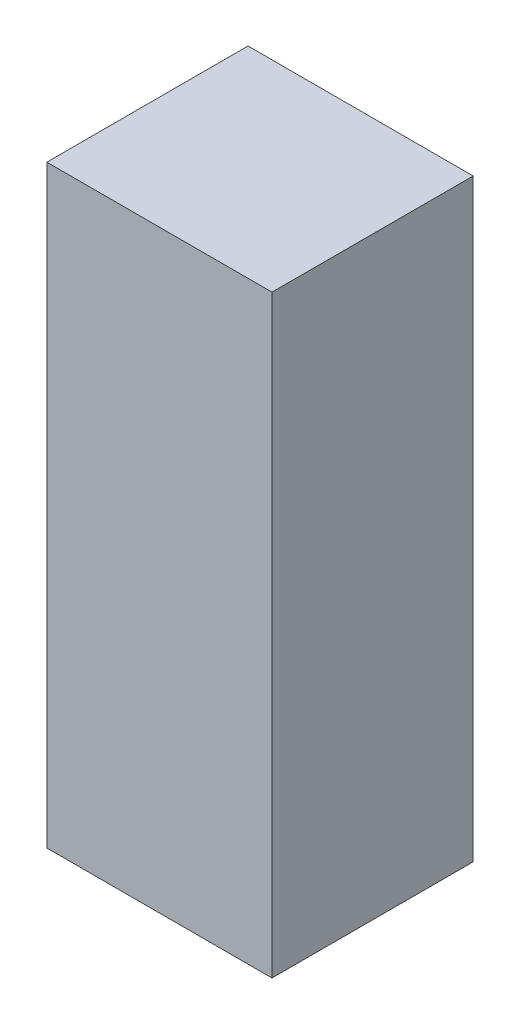
from build123d import *

# Parameters (mm, degrees)
SKETCH1_W           = 596.9
SKETCH1_H           = 533.4
BOSS_EXTRUDE1_DEPTH = 1574.8


with BuildPart() as part:
    # Sketch1 → Boss-Extrude1 (new body)
    with BuildSketch(Plane(origin=(0, 0, 0), x_dir=(1, 0, 0), z_dir=(0, 1, 0))):
        with Locations((298.45, 266.7)):
            Rectangle(SKETCH1_W, SKETCH1_H)
    extrude(amount=BOSS_EXTRUDE1_DEPTH)


solid = part.part
